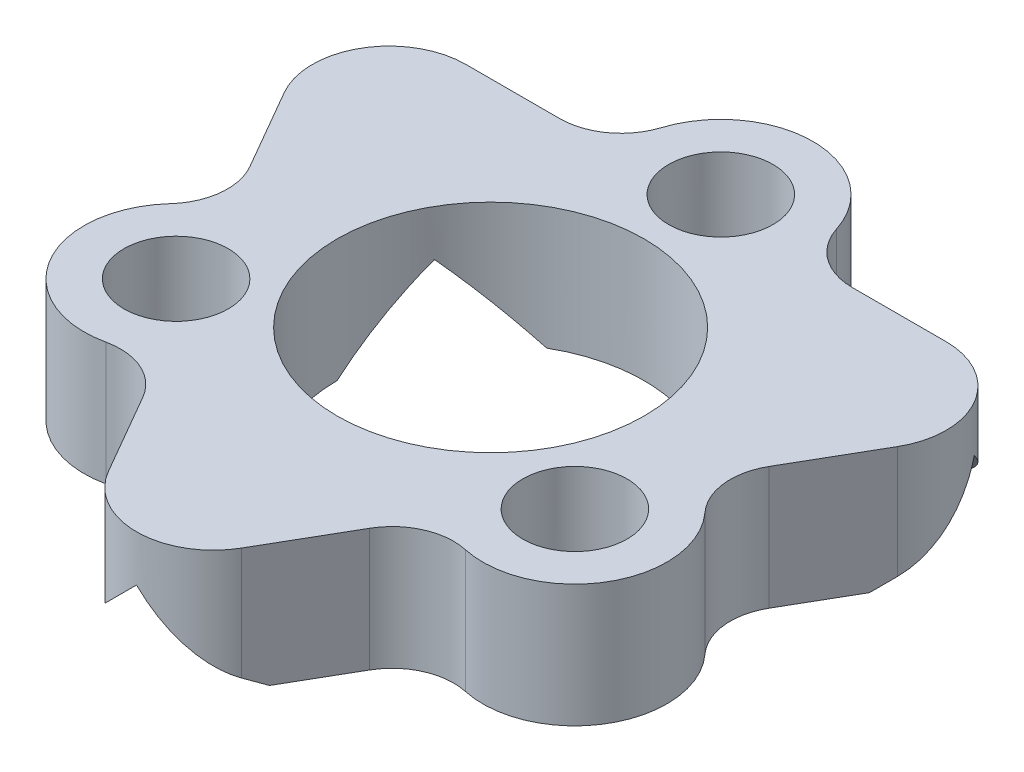
from build123d import *

# Parameters (mm, degrees)
SKETCH1_R         = 5
EXTRUDE1_DEPTH    = 4
CIRPATTERN2_COUNT = 3
EXTRUDE4_START    = 4.45086
EXTRUDE4_DEPTH    = 7.205259
EXTRUDE5_START    = 4.330127
EXTRUDE5_DEPTH    = 7.205258
EXTRUDE6_START    = 4.330127
EXTRUDE6_DEPTH    = 7.205258


with BuildPart() as part:
    # Sketch1 → Extrude1 (new body)
    with BuildSketch(Plane(origin=(0, 0, 0), x_dir=(1, 0, 0), z_dir=(0, 1, 0))):
        with BuildLine():
            Line((-3.89089061, 3.146959138), (-2.360502052, 0.4962484))
            ThreePointArc((-2.360502052, 0.4962484), (-2.104118872, -0.718531203), (-2.613989574, -1.850544314))
            ThreePointArc((-2.613989574, -1.850544314), (-2.994220859, -5.370733384), (0.244467944, -6.801537968))
            ThreePointArc((0.244467944, -6.801537968), (1.479755407, -6.925983542), (2.403593813, -7.75540769))
            Line((2.403593813, -7.75540769), (3.933982371, -10.406118428))
            ThreePointArc((3.933982371, -10.406118428), (6.099045881, -11.656118428), (8.26410939, -10.406118428))
            Line((8.26410939, -10.406118428), (9.794497948, -7.75540769))
            ThreePointArc((9.794497948, -7.75540769), (10.718336354, -6.925983542), (11.953623817, -6.801537968))
            ThreePointArc((11.953623817, -6.801537968), (15.192312621, -5.370733384), (14.812081336, -1.850544314))
            ThreePointArc((14.812081336, -1.850544314), (14.302210633, -0.718531203), (14.558593813, 0.4962484))
            Line((14.558593813, 0.4962484), (16.088982371, 3.146959138))
            ThreePointArc((16.088982371, 3.146959138), (16.088982371, 5.646959138), (13.923918862, 6.896959138))
            Line((13.923918862, 6.896959138), (10.863141746, 6.896959138))
            ThreePointArc((10.863141746, 6.896959138), (9.68292016, 7.282314592), (8.9575034, 8.289882129))
            ThreePointArc((8.9575034, 8.289882129), (6.099045881, 10.379266616), (3.240588362, 8.289882129))
            ThreePointArc((3.240588362, 8.289882129), (2.515171602, 7.282314592), (1.334950016, 6.896959138))
            Line((1.334950016, 6.896959138), (-1.7258271, 6.896959138))
            ThreePointArc((-1.7258271, 6.896959138), (-3.89089061, 5.646959138), (-3.89089061, 3.146959138))
        make_face()
        with Locations((6.099045881, -0.120733384)):
            Circle(SKETCH1_R, mode=Mode.SUBTRACT)
    extrude(amount=EXTRUDE1_DEPTH)

    # Sketch6 → M3 Clearance Hole1 (revolve, cut)
    with BuildSketch(Plane(origin=(-0.396144648, 4, 3.870733384), x_dir=(0, 0, 1), z_dir=(1, 0, 0))):
        Polygon((0, 0), (0, 11.021463052), (1.7, 10), (1.7, 0), align=None)
    m3_clearance_hole1 = revolve(axis=Axis((-0.396144648, 10.35, 3.870733384), (0, -1, 0)), mode=Mode.SUBTRACT)

    # CirPattern2: M3 Clearance Hole1 ×3 about axis
    cirpattern2_axis = Axis((6.099045881, 0, 0.120733384), (0, 1, 0))
    for i in range(1, CIRPATTERN2_COUNT):
        add(m3_clearance_hole1.rotate(cirpattern2_axis, i * 360 / CIRPATTERN2_COUNT), mode=Mode.SUBTRACT)

    # GrooveSketch → Extrude4 (cut)
    with BuildSketch(Plane.XY.offset(EXTRUDE4_START)):
        Polygon((34.668922444, -26.069876563), (8.599045881, 0), (6.099045881, 2.5), (3.599045881, 0), (-22.470830682, -26.069876563), (-22.470830682, -99.806622573), (34.668922444, -99.806622573), align=None)
    extrude(amount=EXTRUDE4_DEPTH, mode=Mode.SUBTRACT)

    # Sketch9 → Extrude5 (cut)
    with BuildSketch(Plane(origin=(4.6265635, 0, 2.671147682), x_dir=(-0.5, 0, 0.866025404), z_dir=(-0.866025404, 0, -0.5)).offset(EXTRUDE5_START)):
        Polygon((32.223222882, -32.668187644), (-0.444964763, 0), (-2.944964763, 2.5), (-5.444964763, 0), (-38.113152407, -32.668187644), (-38.113152407, -125.067775694), (32.223222882, -125.067775694), align=None)
    extrude(amount=EXTRUDE5_DEPTH, mode=Mode.SUBTRACT)

    # Sketch10 → Extrude6 (cut)
    with BuildSketch(Plane(origin=(4.522005322, 0, -2.61078099), x_dir=(-0.5, 0, -0.866025404), z_dir=(0.866025404, 0, -0.5)).offset(EXTRUDE6_START)):
        Polygon((32.014106526, -32.668187644), (-0.654081118, 0), (-3.154081118, 2.5), (-5.654081118, 0), (-38.322268763, -32.668187644), (-38.322268763, -125.067775694), (32.014106526, -125.067775694), align=None)
    extrude(amount=EXTRUDE6_DEPTH, mode=Mode.SUBTRACT)


solid = part.part
